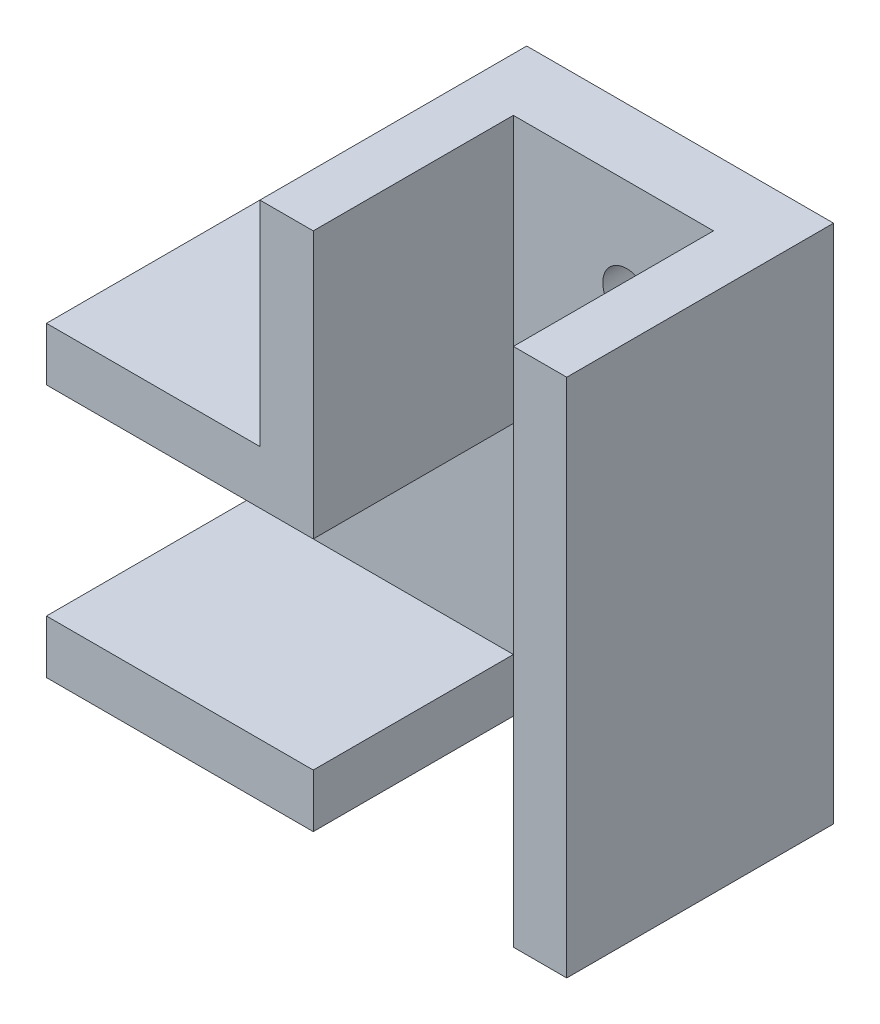
from build123d import *

# Parameters (mm, degrees)
BOSS_EXTRUDE1_DEPTH = 5
BOSS_EXTRUDE2_DEPTH = 20
SKETCH4_W           = 35
SKETCH4_H           = 4
BOSS_EXTRUDE3_DEPTH = 20
SKETCH6_R           = 1.8
CUT_EXTRUDE3_DEPTH  = 6
SKETCH7_W           = 4
SKETCH7_H           = 39
BOSS_EXTRUDE4_DEPTH = 20
SKETCH8_W           = 15
SKETCH8_H           = 15
CUT_EXTRUDE4_DEPTH  = 40


with BuildPart() as part:
    # Sketch1 → Boss-Extrude1 (new body)
    with BuildSketch(Plane.XY):
        Polygon((-20.68627451, -4.264705882), (-0.68627451, -4.264705882), (-0.68627451, 15.735294118), (14.31372549, 15.735294118), (14.31372549, -4.264705882), (14.31372549, -19.264705882), (-20.68627451, -19.264705882), align=None)
    extrude(amount=BOSS_EXTRUDE1_DEPTH)

    # Sketch2 → Boss-Extrude2 (add)
    with BuildSketch(Plane(origin=(0, 0, 0), x_dir=(-1, 0, 0), z_dir=(0, 0, -1))):
        Polygon((0.68627451, 15.735294118), (4.68627451, 15.735294118), (4.68627451, -0.264705882), (6.079970528, -0.264705882), (20.68627451, -0.264705882), (20.68627451, -4.264705882), (0.68627451, -4.264705882), align=None)
    extrude(amount=-BOSS_EXTRUDE2_DEPTH)

    # Sketch4 → Boss-Extrude3 (add)
    with BuildSketch(Plane(origin=(0, 0, 0), x_dir=(-1, 0, 0), z_dir=(0, 0, -1))):
        with Locations((3.18627451, -21.264705882)):
            Rectangle(SKETCH4_W, SKETCH4_H)
    extrude(amount=-BOSS_EXTRUDE3_DEPTH)

    # Sketch6 → Cut-Extrude3 (cut, through all)
    with BuildSketch(Plane.XY.offset(5)):
        with Locations((7.81372549, 8.235294118)):
            Circle(SKETCH6_R)
        with Locations((-13.18627451, -11.764705882)):
            Circle(SKETCH6_R)
    extrude(amount=-CUT_EXTRUDE3_DEPTH, mode=Mode.SUBTRACT)

    # Sketch7 → Boss-Extrude4 (add)
    with BuildSketch(Plane(origin=(0, 0, 0), x_dir=(-1, 0, 0), z_dir=(0, 0, -1))):
        with Locations((-16.31372549, -3.764705882)):
            Rectangle(SKETCH7_W, SKETCH7_H)
    extrude(amount=-BOSS_EXTRUDE4_DEPTH)

    # Sketch8 → Cut-Extrude4 (cut, through all)
    with BuildSketch(Plane(origin=(0, 15.735294118, 0), x_dir=(1, 0, 0), z_dir=(0, 1, 0))):
        with Locations((6.81372549, -12.5)):
            Rectangle(SKETCH8_W, SKETCH8_H)
    extrude(amount=-CUT_EXTRUDE4_DEPTH, mode=Mode.SUBTRACT)


solid = part.part
